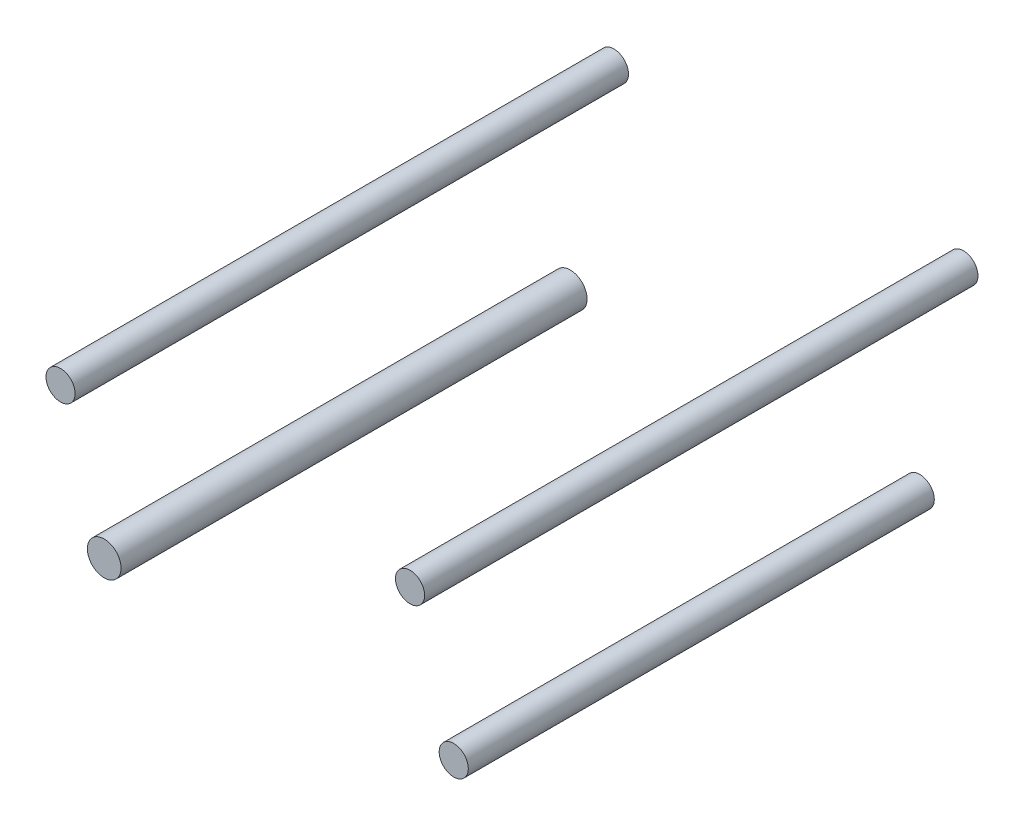
from build123d import *

# Parameters (mm, degrees)
BOSS_EXTRUDE1_DEPTH        = 203.2
BOSS_EXTRUDE1_DEPTH_BACK   = 203.2
SKETCH1_R                  = 12.7
BOSS_EXTRUDE1_2_DEPTH      = 203.2
BOSS_EXTRUDE1_2_DEPTH_BACK = 203.2
SKETCH1_R_2                = 14.694266488
BOSS_EXTRUDE2_DEPTH        = 241.3
BOSS_EXTRUDE2_DEPTH_BACK   = 241.3
SKETCH1_3_R                = 12.7
BOSS_EXTRUDE2_2_DEPTH      = 241.3
BOSS_EXTRUDE2_2_DEPTH_BACK = 241.3


with BuildPart() as part:
    # Sketch1 → Boss-Extrude1 (new, two sides: drawn at the far end of the back side and taken through both)
    with BuildSketch(Plane.XY.offset(-BOSS_EXTRUDE1_DEPTH_BACK)):
        with Locations((152.4, -74.93)):
            Circle(SKETCH1_R)
    extrude(amount=BOSS_EXTRUDE1_DEPTH + BOSS_EXTRUDE1_DEPTH_BACK)


with BuildPart() as body_2:
    # Sketch1 → Boss-Extrude1 2 (new, two sides: drawn at the far end of the back side and taken through both)
    with BuildSketch(Plane.XY.offset(-BOSS_EXTRUDE1_2_DEPTH_BACK)):
        with Locations((-152.4, -74.93)):
            Circle(SKETCH1_R_2)
    extrude(amount=BOSS_EXTRUDE1_2_DEPTH + BOSS_EXTRUDE1_2_DEPTH_BACK)


with BuildPart() as body_3:
    # Sketch1_3 → Boss-Extrude2 (new, two sides: drawn at the far end of the back side and taken through both)
    with BuildSketch(Plane.XY.offset(-BOSS_EXTRUDE2_DEPTH_BACK)):
        with Locations((-152.4, 74.93)):
            Circle(SKETCH1_3_R)
    extrude(amount=BOSS_EXTRUDE2_DEPTH + BOSS_EXTRUDE2_DEPTH_BACK)


with BuildPart() as body_4:
    # Sketch1_3 → Boss-Extrude2 2 (new, two sides: drawn at the far end of the back side and taken through both)
    with BuildSketch(Plane.XY.offset(-BOSS_EXTRUDE2_2_DEPTH_BACK)):
        with Locations((152.4, 74.93)):
            Circle(SKETCH1_3_R)
    extrude(amount=BOSS_EXTRUDE2_2_DEPTH + BOSS_EXTRUDE2_2_DEPTH_BACK)


solid = Compound([part.part, body_2.part, body_3.part, body_4.part])
